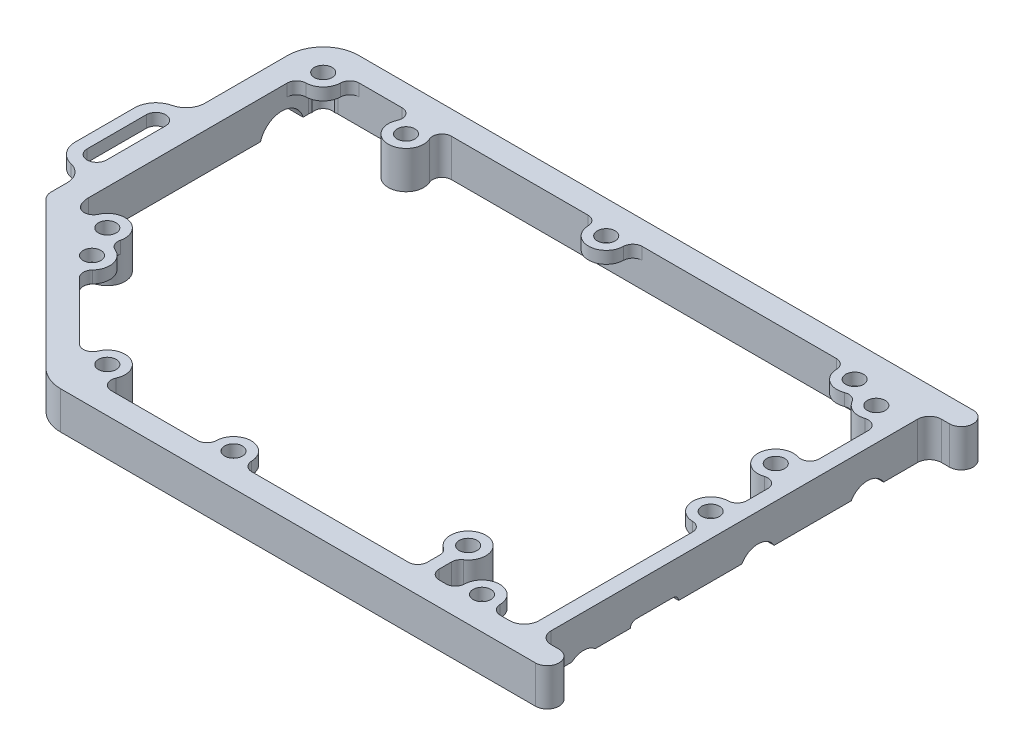
from build123d import *

# Parameters (mm, degrees)
BOSS_EXTRUDE1_DEPTH = 6.35
BOSS_EXTRUDE2_DEPTH = 2
SKETCH3_R           = 3
BOSS_EXTRUDE3_DEPTH = 6.35
BOSS_EXTRUDE4_DEPTH = 6.35
SKETCH5_R           = 1.5
CUT_EXTRUDE1_DEPTH  = 7.35
BOSS_EXTRUDE5_DEPTH = 2.05
SKETCH8_R           = 1.5
CUT_EXTRUDE2_DEPTH  = 7.35
SKETCH9_R           = 2.998526721
SKETCH9_R_2         = 3.175
CUT_EXTRUDE3_DEPTH  = 12.5
SKETCH10_R          = 3.75
CUT_EXTRUDE4_DEPTH  = 12.5


with BuildPart() as part:
    # Sketch1 → Boss-Extrude1 (new body)
    with BuildSketch(Plane(origin=(0, 0, 0), x_dir=(1, 0, 0), z_dir=(0, 1, 0))):
        with BuildLine():
            Line((-103.376996149, 22.013035118), (-78.621320344, -2.742640687))
            ThreePointArc((-78.621320344, -2.742640687), (-76.674780251, -4.043277195), (-74.378679656, -4.5))
            Line((-74.378679656, -4.5), (5.87, -4.5))
            ThreePointArc((5.87, -4.5), (7.284213562, -3.914213562), (7.87, -2.5))
            ThreePointArc((7.87, -2.5), (7.284213562, -1.085786438), (5.87, -0.5))
            Line((5.87, -0.5), (4.5, -0.5))
            ThreePointArc((4.5, -0.5), (3.085786438, 0.085786438), (2.5, 1.5))
            Line((2.5, 1.5), (2.5, 63.5))
            ThreePointArc((2.5, 63.5), (3.085786438, 64.914213562), (4.5, 65.5))
            Line((4.5, 65.5), (5.87, 65.5))
            ThreePointArc((5.87, 65.5), (7.284213562, 66.085786438), (7.87, 67.5))
            ThreePointArc((7.87, 67.5), (7.284213562, 68.914213562), (5.87, 69.5))
            Line((5.87, 69.5), (-98, 69.5))
            ThreePointArc((-98, 69.5), (-102.242640687, 67.742640687), (-104, 63.5))
            Line((-104, 63.5), (-104, 23.517099465))
            ThreePointArc((-104, 23.517099465), (-103.838086574, 22.703105706), (-103.376996149, 22.013035118))
        make_face()
        with BuildLine():
            Line((-2.5, -0.5), (-74.171572609, -0.5))
            ThreePointArc((-74.171572609, -0.5), (-75.128281436, -0.309698782), (-75.939340016, 0.232233235))
            Line((-75.939340016, 0.232233235), (-98.914213415, 23.207106634))
            ThreePointArc((-98.914213415, 23.207106634), (-99.71781326, 24.409778793), (-100, 25.828427333))
            Line((-100, 25.828427333), (-100.000000002, 62.999999997))
            ThreePointArc((-100.000000002, 62.999999997), (-99.267766954, 64.767766952), (-97.499999999, 65.5))
            Line((-97.499999999, 65.5), (-2.5, 65.5))
            ThreePointArc((-2.5, 65.5), (-0.732233047, 64.767766953), (0, 63))
            Line((0, 63), (0, 2))
            ThreePointArc((0, 2), (-0.732233047, 0.232233047), (-2.5, -0.5))
        make_face(mode=Mode.SUBTRACT)
    extrude(amount=BOSS_EXTRUDE1_DEPTH)

    # Sketch2 → Boss-Extrude2 (add)
    with BuildSketch(Plane.XZ.offset(-6.35)):
        with BuildLine():
            Line((-107.275, -32.863265107), (-107.275, -42.863265107))
            ThreePointArc((-107.275, -42.863265107), (-105.6375, -44.500765107), (-104, -42.863265107))
            Line((-104, -42.863265107), (-104, -49.499999997))
            ThreePointArc((-104, -49.499999997), (-104.689471703, -47.524456001), (-106.458440367, -46.406916214))
            ThreePointArc((-106.458440367, -46.406916214), (-108.485093443, -45.126585198), (-109.275, -42.863265107))
            Line((-109.275, -42.863265107), (-109.275, -32.863265107))
            ThreePointArc((-109.275, -32.863265107), (-108.485093443, -30.599945017), (-106.458440367, -29.319614001))
            ThreePointArc((-106.458440367, -29.319614001), (-104.689471703, -28.202074214), (-104, -26.226530217))
            Line((-104, -26.226530217), (-104, -32.863265107))
            ThreePointArc((-104, -32.863265107), (-105.6375, -31.225765107), (-107.275, -32.863265107))
        make_face()
    extrude(amount=BOSS_EXTRUDE2_DEPTH)

    # Sketch3 → Boss-Extrude3 (add)
    with BuildSketch(Plane(origin=(0, 6.35, 0), x_dir=(1, 0, 0), z_dir=(0, 1, 0))):
        with Locations(Location((-17, 7, 0), (0, 0, 270))):  # turned: the seam where the file's is
            Circle(SKETCH3_R)
        with BuildLine():
            Line((-86.669832131, 65.5), (-78.330167869, 65.5))
            ThreePointArc((-78.330167869, 65.5), (-79.66635528, 64.769681108), (-79.773134301, 63.250681199))
            ThreePointArc((-79.773134301, 63.250681199), (-82.5, 59), (-85.226865699, 63.250681199))
            ThreePointArc((-85.226865699, 63.250681199), (-85.33364472, 64.769681108), (-86.669832131, 65.5))
        make_face()
        with BuildLine():
            Line((-99.604595888, 24.162514215), (-99.142222647, 20.840701815))
            Line((-99.142222647, 20.840701815), (-93.352359545, 17.645252764))
            ThreePointArc((-93.352359545, 17.645252764), (-93.787356109, 19.074804281), (-92.842394025, 20.23233882))
            ThreePointArc((-92.842394025, 20.23233882), (-91.852205251, 25.094511332), (-96.737713595, 24.226753551))
            ThreePointArc((-96.737713595, 24.226753551), (-98.150857575, 23.288809022), (-99.604595888, 24.162514215))
        make_face()
        with BuildLine():
            Line((-79.354747236, 3.647640455), (-74.752525271, -2.046501885))
            Line((-74.752525271, -2.046501885), (-69.830167869, -0.5))
            ThreePointArc((-69.830167869, -0.5), (-71.16635528, 0.230318892), (-71.273134301, 1.749318801))
            ThreePointArc((-71.273134301, 1.749318801), (-72.79568366, 5.747657576), (-76.76766118, 4.157605975))
            ThreePointArc((-76.76766118, 4.157605975), (-77.925195719, 3.212643891), (-79.354747236, 3.647640455))
        make_face()
        with BuildLine():
            Line((0, 49.364630569), (0, 40.635369431))
            ThreePointArc((0, 40.635369431), (-0.653638304, 41.919136771), (-2.076294278, 42.145745677))
            ThreePointArc((-2.076294278, 42.145745677), (-3.373353308, 42.023322774), (-4.6, 42.462284492))
            ThreePointArc((-4.6, 42.462284492), (-6, 45), (-4.6, 47.537715508))
            ThreePointArc((-4.6, 47.537715508), (-3.373353308, 47.976677226), (-2.076294278, 47.854254323))
            ThreePointArc((-2.076294278, 47.854254323), (-0.653638304, 48.080863229), (0, 49.364630569))
        make_face()
        with BuildLine():
            Line((-7.169832131, 65.5), (1.143874295, 66.657210257))
            Line((1.143874295, 66.657210257), (0, 57.635369431))
            ThreePointArc((0, 57.635369431), (-0.653638304, 58.919136771), (-2.076294278, 59.145745677))
            ThreePointArc((-2.076294278, 59.145745677), (-5.241756094, 60.006377765), (-5.726865699, 63.250681199))
            ThreePointArc((-5.726865699, 63.250681199), (-5.83364472, 64.769681108), (-7.169832131, 65.5))
        make_face()
    extrude(amount=-BOSS_EXTRUDE3_DEPTH)

    # Sketch4 → Boss-Extrude4 (add)
    with BuildSketch(Plane(origin=(0, 6.35, 0), x_dir=(1, 0, 0), z_dir=(0, 1, 0))):
        with BuildLine():
            ThreePointArc((-18.692098093, 4.522742637), (-18.183646949, 3.953044034), (-18, 3.211860615))
            Line((-18, 3.211860615), (-18, 1.0875))
            ThreePointArc((-18, 1.0875), (-18.464967985, -0.035032015), (-19.5875, -0.5))
            Line((-19.5875, -0.5), (-14.4125, -0.5))
            ThreePointArc((-14.4125, -0.5), (-15.535032015, -0.035032015), (-16, 1.0875))
            Line((-16, 1.0875), (-16, 3.211860615))
            ThreePointArc((-16, 3.211860615), (-15.816353051, 3.953044034), (-15.307901907, 4.522742637))
            ThreePointArc((-15.307901907, 4.522742637), (-17, 4), (-18.692098093, 4.522742637))
        make_face()
    extrude(amount=-BOSS_EXTRUDE4_DEPTH)

    # Sketch5 → Cut-Extrude1 (cut, through all)
    with BuildSketch(Plane(origin=(0, 6.35, 0), x_dir=(1, 0, 0), z_dir=(0, 1, 0))):
        with Locations(Location((-82.5, 62, 0), (0, 0, 270))):  # turned: the seam where the file's is
            Circle(SKETCH5_R)
        with Locations(Location((-94, 23, 0), (0, 0, 270))):  # turned: the seam where the file's is
            Circle(SKETCH5_R)
        with Locations(Location((-74, 3, 0), (0, 0, 270))):  # turned: the seam where the file's is
            Circle(SKETCH5_R)
        with Locations(Location((-17, 7, 0), (0, 0, 270))):  # turned: the seam where the file's is
            Circle(SKETCH5_R)
        with Locations(Location((-3, 45, 0), (0, 0, 270))):  # turned: the seam where the file's is
            Circle(SKETCH5_R)
        with Locations(Location((-3, 62, 0), (0, 0, 270))):  # turned: the seam where the file's is
            Circle(SKETCH5_R)
    extrude(amount=-CUT_EXTRUDE1_DEPTH, mode=Mode.SUBTRACT)

    # Sketch7 → Boss-Extrude5 (add)
    with BuildSketch(Plane(origin=(0, 6.35, 0), x_dir=(1, 0, 0), z_dir=(0, 1, 0))):
        with BuildLine():
            Line((-55.243519705, 65.5), (-46.070188794, 65.5))
            ThreePointArc((-46.070188794, 65.5), (-47.181963923, 65.045686795), (-47.657400001, 63.942779292))
            ThreePointArc((-47.657400001, 63.942779292), (-50.656854249, 61), (-53.656308498, 63.942779292))
            ThreePointArc((-53.656308498, 63.942779292), (-54.131744576, 65.045686795), (-55.243519705, 65.5))
        make_face()
        with BuildLine():
            Line((-5.606189561, 60.514141336), (-4.385713879, 66.734981309))
            Line((-4.385713879, 66.734981309), (-13.243519705, 65.5))
            ThreePointArc((-13.243519705, 65.5), (-12.131744576, 65.045686795), (-11.656308498, 63.942779292))
            ThreePointArc((-11.656308498, 63.942779292), (-10.324395643, 61.506146416), (-7.56373858, 61.206239428))
            ThreePointArc((-7.56373858, 61.206239428), (-6.456131538, 61.224583813), (-5.606189561, 60.514141336))
        make_face()
        with BuildLine():
            Line((0, 27.913334545), (0, 37.086665455))
            ThreePointArc((0, 37.086665455), (-0.454313205, 35.974890326), (-1.557220708, 35.499454249))
            ThreePointArc((-1.557220708, 35.499454249), (-4.5, 32.5), (-1.557220708, 29.500545751))
            ThreePointArc((-1.557220708, 29.500545751), (-0.454313205, 29.025109674), (0, 27.913334545))
        make_face()
        with BuildLine():
            Line((-13.243519705, -0.5), (-4.070188794, -0.5))
            ThreePointArc((-4.070188794, -0.5), (-5.181963923, -0.045686795), (-5.657400001, 1.057220708))
            ThreePointArc((-5.657400001, 1.057220708), (-8.656854249, 4), (-11.656308498, 1.057220708))
            ThreePointArc((-11.656308498, 1.057220708), (-12.131744576, -0.045686795), (-13.243519705, -0.5))
        make_face()
        with BuildLine():
            Line((-55.243519705, -0.5), (-46.070188794, -0.5))
            ThreePointArc((-46.070188794, -0.5), (-47.181963923, -0.045686795), (-47.657400001, 1.057220708))
            ThreePointArc((-47.657400001, 1.057220708), (-50.656854249, 4), (-53.656308498, 1.057220708))
            ThreePointArc((-53.656308498, 1.057220708), (-54.131744576, -0.045686795), (-55.243519705, -0.5))
        make_face()
        with BuildLine():
            Line((-91.083902249, 22.295461919), (-96.153243781, 18.294878566))
            Line((-96.153243781, 18.294878566), (-89.069446291, 13.36233951))
            ThreePointArc((-89.069446291, 13.36233951), (-89.534342076, 14.469731191), (-89.090652776, 15.58578864))
            ThreePointArc((-89.090652776, 15.58578864), (-88.318647418, 18.294878566), (-90.132976207, 20.449726946))
            ThreePointArc((-90.132976207, 20.449726946), (-90.952018721, 21.195581648), (-91.083902249, 22.295461919))
        make_face()
        with BuildLine():
            Line((-100.000000001, 59.413334545), (-101.020805501, 66.734981309))
            Line((-101.020805501, 66.734981309), (-93.913334545, 65.5))
            ThreePointArc((-93.913334545, 65.5), (-95.025109674, 65.045686795), (-95.500545751, 63.942779292))
            ThreePointArc((-95.500545751, 63.942779292), (-96.378679656, 61.878679656), (-98.442779292, 61.000545751))
            ThreePointArc((-98.442779292, 61.000545751), (-99.545686795, 60.525109674), (-100.000000001, 59.413334545))
        make_face()
    extrude(amount=-BOSS_EXTRUDE5_DEPTH)

    # Sketch8 → Cut-Extrude2 (cut, through all)
    with BuildSketch(Plane(origin=(0, 6.35, 0), x_dir=(1, 0, 0), z_dir=(0, 1, 0))):
        with Locations(Location((-98.5, 64, 0), (0, 0, 270))):  # turned: the seam where the file's is
            Circle(SKETCH8_R)
        with Locations(Location((-50.656854249, 64, 0), (0, 0, 270))):  # turned: the seam where the file's is
            Circle(SKETCH8_R)
        with Locations(Location((-91.252048366, 17.666261928, 0), (0, 0, 270))):  # turned: the seam where the file's is
            Circle(SKETCH8_R)
        with Locations(Location((-50.656854249, 1, 0), (0, 0, 270))):  # turned: the seam where the file's is
            Circle(SKETCH8_R)
        with Locations(Location((-8.656854249, 1, 0), (0, 0, 270))):  # turned: the seam where the file's is
            Circle(SKETCH8_R)
        with Locations(Location((-1.5, 32.5, 0), (0, 0, 270))):  # turned: the seam where the file's is
            Circle(SKETCH8_R)
        with Locations(Location((-8.656854249, 64, 0), (0, 0, 270))):  # turned: the seam where the file's is
            Circle(SKETCH8_R)
    extrude(amount=-CUT_EXTRUDE2_DEPTH, mode=Mode.SUBTRACT)

    # Sketch9 → Cut-Extrude3 (cut)
    with BuildSketch(Plane(origin=(2.5, 0, 0), x_dir=(0, 0, -1), z_dir=(1, 0, 0))):
        with Locations((6.999655348, -2.26)):
            Circle(SKETCH9_R)
        with Locations((36.5, -1.605)):
            Circle(SKETCH9_R_2)
        with Locations((55, -1.605)):
            Circle(SKETCH9_R_2)
        with BuildLine():
            Line((15.2, -2.43), (22.8, -2.43))
            ThreePointArc((22.8, -2.43), (23.012132034, -2.342132034), (23.1, -2.13))
            Line((23.1, -2.13), (23.1, -0.1))
            ThreePointArc((23.1, -0.1), (22.807106781, 0.607106781), (22.1, 0.9))
            Line((22.1, 0.9), (15.9, 0.9))
            ThreePointArc((15.9, 0.9), (15.192893219, 0.607106781), (14.9, -0.1))
            Line((14.9, -0.1), (14.9, -2.13))
            ThreePointArc((14.9, -2.13), (14.987867966, -2.342132034), (15.2, -2.43))
        make_face()
    extrude(amount=-CUT_EXTRUDE3_DEPTH, mode=Mode.SUBTRACT)

    # Sketch10 → Cut-Extrude4 (cut)
    with BuildSketch(Plane.ZY.offset(104)):
        with Locations((-58.499999997, -1.05)):
            Circle(SKETCH10_R)
    extrude(amount=-CUT_EXTRUDE4_DEPTH, mode=Mode.SUBTRACT)


solid = part.part
